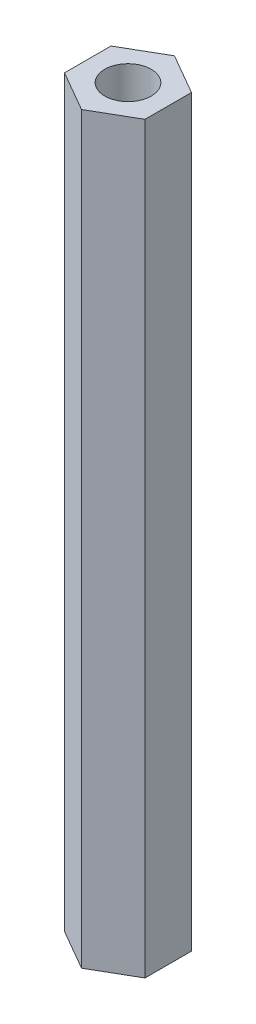
from build123d import *

# Parameters (mm, degrees)
ESQUISSE1_R      = 2.5
EXTRUSION1_DEPTH = 80


with BuildPart() as part:
    # Esquisse1 → Extrusion1 (new body)
    with BuildSketch(Plane(origin=(0, 0, 0), x_dir=(1, 0, 0), z_dir=(0, 1, 0))):
        Polygon((0, 5), (-4.330127019, 2.5), (-4.330127019, -2.5), (0, -5), (4.330127019, -2.5), (4.330127019, 2.5), align=None)
        Circle(ESQUISSE1_R, mode=Mode.SUBTRACT)
    extrude(amount=EXTRUSION1_DEPTH)


solid = part.part
